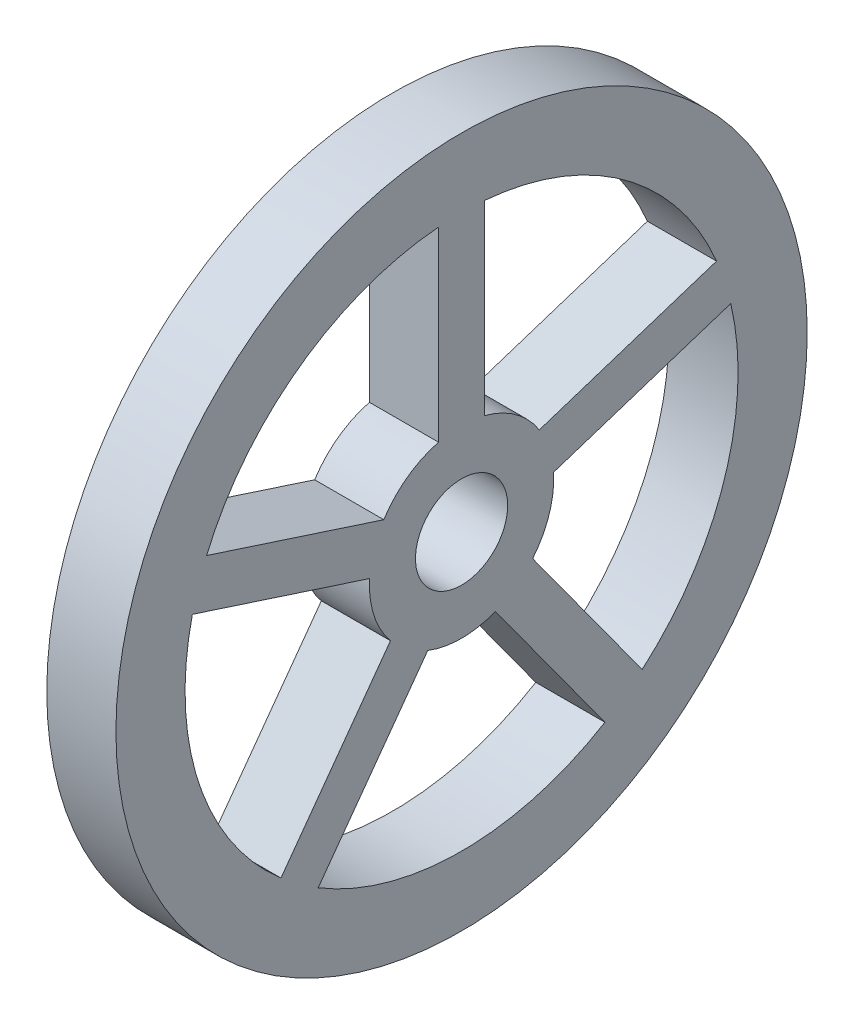
from build123d import *

# Parameters (mm, degrees)
SKETCH1_R           = 150
SKETCH1_R_2         = 20
BOSS_EXTRUDE1_DEPTH = 30


with BuildPart() as part:
    # Sketch1 → Boss-Extrude1 (new body)
    with BuildSketch(Plane(origin=(0, 0, 0), x_dir=(0, 0, -1), z_dir=(1, 0, 0))):
        Circle(SKETCH1_R)
        Circle(SKETCH1_R_2, mode=Mode.SUBTRACT)
        with BuildLine():
            Line((110.639648089, 46.463623091), (33.744090545, 21.478741892))
            ThreePointArc((33.744090545, 21.478741892), (23.511410092, 32.360679775), (10, 38.729833462))
            Line((10, 38.729833462), (10, 119.582607431))
            ThreePointArc((10, 119.582607431), (70.534230275, 97.082039325), (110.639648089, 46.463623091))
        make_face(mode=Mode.SUBTRACT)
        with BuildLine():
            Line((-10, 119.582607431), (-10, 38.729833462))
            ThreePointArc((-10, 38.729833462), (-23.511410092, 32.360679775), (-33.744090545, 21.478741892))
            Line((-33.744090545, 21.478741892), (-110.639648089, 46.463623091))
            ThreePointArc((-110.639648089, 46.463623091), (-70.534230275, 97.082039325), (-10, 119.582607431))
        make_face(mode=Mode.SUBTRACT)
        with BuildLine():
            Line((116.819987977, 27.442492765), (39.924430433, 2.457611566))
            ThreePointArc((39.924430433, 2.457611566), (38.042260652, -12.360679775), (30.854994877, -25.455240937))
            Line((30.854994877, -25.455240937), (78.379063022, -90.86650912))
            ThreePointArc((78.379063022, -90.86650912), (114.126781955, -37.082039325), (116.819987977, 27.442492765))
        make_face(mode=Mode.SUBTRACT)
        with BuildLine():
            Line((62.198723135, -102.622214166), (14.674654989, -37.210945983))
            ThreePointArc((14.674654989, -37.210945983), (0, -40), (-14.674654989, -37.210945983))
            Line((-14.674654989, -37.210945983), (-62.198723135, -102.622214166))
            ThreePointArc((-62.198723135, -102.622214166), (0, -120), (62.198723135, -102.622214166))
        make_face(mode=Mode.SUBTRACT)
        with BuildLine():
            Line((-78.379063022, -90.86650912), (-30.854994877, -25.455240937))
            ThreePointArc((-30.854994877, -25.455240937), (-38.042260652, -12.360679775), (-39.924430433, 2.457611566))
            Line((-39.924430433, 2.457611566), (-116.819987977, 27.442492765))
            ThreePointArc((-116.819987977, 27.442492765), (-114.126781955, -37.082039325), (-78.379063022, -90.86650912))
        make_face(mode=Mode.SUBTRACT)
    extrude(amount=BOSS_EXTRUDE1_DEPTH)


solid = part.part
